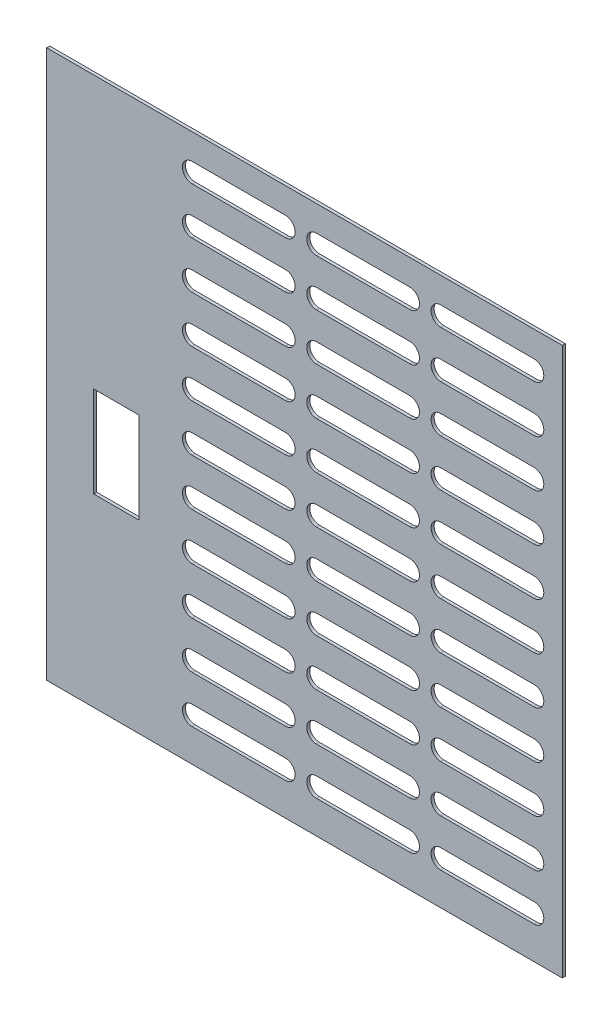
from build123d import *

# Parameters (mm, degrees)
ESBO_O1_W                = 170
ESBO_O1_H                = 180.654713277
RESSALTO_EXTRUS_O1_DEPTH = 1


with BuildPart() as part:
    # Esboço1 → Ressalto-extrusão1 (new body)
    with BuildSketch(Plane.XY):
        with Locations((-120, 100.327356639)):
            Rectangle(ESBO_O1_W, ESBO_O1_H)
        with BuildLine():
            Line((-116.056042092, 182.171109309), (-85.285782991, 182.171109309))
            ThreePointArc((-85.285782991, 182.171109309), (-82.089523647, 178.974849965), (-85.285782991, 175.778590621))
            Line((-85.285782991, 175.778590621), (-116.056042092, 175.778590621))
            ThreePointArc((-116.056042092, 175.778590621), (-119.252301436, 178.974849965), (-116.056042092, 182.171109309))
        make_face(mode=Mode.SUBTRACT)
        with BuildLine():
            Line((-75.056042092, 182.171109309), (-44.285782991, 182.171109309))
            ThreePointArc((-44.285782991, 182.171109309), (-41.089523647, 178.974849965), (-44.285782991, 175.778590621))
            Line((-44.285782991, 175.778590621), (-75.056042092, 175.778590621))
            ThreePointArc((-75.056042092, 175.778590621), (-78.252301436, 178.974849965), (-75.056042092, 182.171109309))
        make_face(mode=Mode.SUBTRACT)
        with BuildLine():
            Line((-157.056042092, 182.171109309), (-126.285782991, 182.171109309))
            ThreePointArc((-126.285782991, 182.171109309), (-123.089523647, 178.974849965), (-126.285782991, 175.778590621))
            Line((-126.285782991, 175.778590621), (-157.056042092, 175.778590621))
            ThreePointArc((-157.056042092, 175.778590621), (-160.252301436, 178.974849965), (-157.056042092, 182.171109309))
        make_face(mode=Mode.SUBTRACT)
        with BuildLine():
            Line((-116.056042092, 166.671109309), (-85.285782991, 166.671109309))
            ThreePointArc((-85.285782991, 166.671109309), (-82.089523647, 163.474849965), (-85.285782991, 160.278590621))
            Line((-85.285782991, 160.278590621), (-116.056042092, 160.278590621))
            ThreePointArc((-116.056042092, 160.278590621), (-119.252301436, 163.474849965), (-116.056042092, 166.671109309))
        make_face(mode=Mode.SUBTRACT)
        with BuildLine():
            Line((-75.056042092, 166.671109309), (-44.285782991, 166.671109309))
            ThreePointArc((-44.285782991, 166.671109309), (-41.089523647, 163.474849965), (-44.285782991, 160.278590621))
            Line((-44.285782991, 160.278590621), (-75.056042092, 160.278590621))
            ThreePointArc((-75.056042092, 160.278590621), (-78.252301436, 163.474849965), (-75.056042092, 166.671109309))
        make_face(mode=Mode.SUBTRACT)
        with BuildLine():
            Line((-116.056042092, 151.171109309), (-85.285782991, 151.171109309))
            ThreePointArc((-85.285782991, 151.171109309), (-82.089523647, 147.974849965), (-85.285782991, 144.778590621))
            Line((-85.285782991, 144.778590621), (-116.056042092, 144.778590621))
            ThreePointArc((-116.056042092, 144.778590621), (-119.252301436, 147.974849965), (-116.056042092, 151.171109309))
        make_face(mode=Mode.SUBTRACT)
        with BuildLine():
            Line((-75.056042092, 151.171109309), (-44.285782991, 151.171109309))
            ThreePointArc((-44.285782991, 151.171109309), (-41.089523647, 147.974849965), (-44.285782991, 144.778590621))
            Line((-44.285782991, 144.778590621), (-75.056042092, 144.778590621))
            ThreePointArc((-75.056042092, 144.778590621), (-78.252301436, 147.974849965), (-75.056042092, 151.171109309))
        make_face(mode=Mode.SUBTRACT)
        with BuildLine():
            Line((-116.056042092, 135.671109309), (-85.285782991, 135.671109309))
            ThreePointArc((-85.285782991, 135.671109309), (-82.089523647, 132.474849965), (-85.285782991, 129.278590621))
            Line((-85.285782991, 129.278590621), (-116.056042092, 129.278590621))
            ThreePointArc((-116.056042092, 129.278590621), (-119.252301436, 132.474849965), (-116.056042092, 135.671109309))
        make_face(mode=Mode.SUBTRACT)
        with BuildLine():
            Line((-75.056042092, 135.671109309), (-44.285782991, 135.671109309))
            ThreePointArc((-44.285782991, 135.671109309), (-41.089523647, 132.474849965), (-44.285782991, 129.278590621))
            Line((-44.285782991, 129.278590621), (-75.056042092, 129.278590621))
            ThreePointArc((-75.056042092, 129.278590621), (-78.252301436, 132.474849965), (-75.056042092, 135.671109309))
        make_face(mode=Mode.SUBTRACT)
        with BuildLine():
            Line((-116.056042092, 120.171109309), (-85.285782991, 120.171109309))
            ThreePointArc((-85.285782991, 120.171109309), (-82.089523647, 116.974849965), (-85.285782991, 113.778590621))
            Line((-85.285782991, 113.778590621), (-116.056042092, 113.778590621))
            ThreePointArc((-116.056042092, 113.778590621), (-119.252301436, 116.974849965), (-116.056042092, 120.171109309))
        make_face(mode=Mode.SUBTRACT)
        with BuildLine():
            Line((-75.056042092, 120.171109309), (-44.285782991, 120.171109309))
            ThreePointArc((-44.285782991, 120.171109309), (-41.089523647, 116.974849965), (-44.285782991, 113.778590621))
            Line((-44.285782991, 113.778590621), (-75.056042092, 113.778590621))
            ThreePointArc((-75.056042092, 113.778590621), (-78.252301436, 116.974849965), (-75.056042092, 120.171109309))
        make_face(mode=Mode.SUBTRACT)
        with BuildLine():
            Line((-116.056042092, 104.671109309), (-85.285782991, 104.671109309))
            ThreePointArc((-85.285782991, 104.671109309), (-82.089523647, 101.474849965), (-85.285782991, 98.278590621))
            Line((-85.285782991, 98.278590621), (-116.056042092, 98.278590621))
            ThreePointArc((-116.056042092, 98.278590621), (-119.252301436, 101.474849965), (-116.056042092, 104.671109309))
        make_face(mode=Mode.SUBTRACT)
        with BuildLine():
            Line((-75.056042092, 104.671109309), (-44.285782991, 104.671109309))
            ThreePointArc((-44.285782991, 104.671109309), (-41.089523647, 101.474849965), (-44.285782991, 98.278590621))
            Line((-44.285782991, 98.278590621), (-75.056042092, 98.278590621))
            ThreePointArc((-75.056042092, 98.278590621), (-78.252301436, 101.474849965), (-75.056042092, 104.671109309))
        make_face(mode=Mode.SUBTRACT)
        with BuildLine():
            Line((-116.056042092, 89.171109309), (-85.285782991, 89.171109309))
            ThreePointArc((-85.285782991, 89.171109309), (-82.089523647, 85.974849965), (-85.285782991, 82.778590621))
            Line((-85.285782991, 82.778590621), (-116.056042092, 82.778590621))
            ThreePointArc((-116.056042092, 82.778590621), (-119.252301436, 85.974849965), (-116.056042092, 89.171109309))
        make_face(mode=Mode.SUBTRACT)
        with BuildLine():
            Line((-75.056042092, 89.171109309), (-44.285782991, 89.171109309))
            ThreePointArc((-44.285782991, 89.171109309), (-41.089523647, 85.974849965), (-44.285782991, 82.778590621))
            Line((-44.285782991, 82.778590621), (-75.056042092, 82.778590621))
            ThreePointArc((-75.056042092, 82.778590621), (-78.252301436, 85.974849965), (-75.056042092, 89.171109309))
        make_face(mode=Mode.SUBTRACT)
        with BuildLine():
            Line((-116.056042092, 73.671109309), (-85.285782991, 73.671109309))
            ThreePointArc((-85.285782991, 73.671109309), (-82.089523647, 70.474849965), (-85.285782991, 67.278590621))
            Line((-85.285782991, 67.278590621), (-116.056042092, 67.278590621))
            ThreePointArc((-116.056042092, 67.278590621), (-119.252301436, 70.474849965), (-116.056042092, 73.671109309))
        make_face(mode=Mode.SUBTRACT)
        with BuildLine():
            Line((-75.056042092, 73.671109309), (-44.285782991, 73.671109309))
            ThreePointArc((-44.285782991, 73.671109309), (-41.089523647, 70.474849965), (-44.285782991, 67.278590621))
            Line((-44.285782991, 67.278590621), (-75.056042092, 67.278590621))
            ThreePointArc((-75.056042092, 67.278590621), (-78.252301436, 70.474849965), (-75.056042092, 73.671109309))
        make_face(mode=Mode.SUBTRACT)
        with BuildLine():
            Line((-116.056042092, 58.171109309), (-85.285782991, 58.171109309))
            ThreePointArc((-85.285782991, 58.171109309), (-82.089523647, 54.974849965), (-85.285782991, 51.778590621))
            Line((-85.285782991, 51.778590621), (-116.056042092, 51.778590621))
            ThreePointArc((-116.056042092, 51.778590621), (-119.252301436, 54.974849965), (-116.056042092, 58.171109309))
        make_face(mode=Mode.SUBTRACT)
        with BuildLine():
            Line((-75.056042092, 58.171109309), (-44.285782991, 58.171109309))
            ThreePointArc((-44.285782991, 58.171109309), (-41.089523647, 54.974849965), (-44.285782991, 51.778590621))
            Line((-44.285782991, 51.778590621), (-75.056042092, 51.778590621))
            ThreePointArc((-75.056042092, 51.778590621), (-78.252301436, 54.974849965), (-75.056042092, 58.171109309))
        make_face(mode=Mode.SUBTRACT)
        with BuildLine():
            Line((-116.056042092, 42.671109309), (-85.285782991, 42.671109309))
            ThreePointArc((-85.285782991, 42.671109309), (-82.089523647, 39.474849965), (-85.285782991, 36.278590621))
            Line((-85.285782991, 36.278590621), (-116.056042092, 36.278590621))
            ThreePointArc((-116.056042092, 36.278590621), (-119.252301436, 39.474849965), (-116.056042092, 42.671109309))
        make_face(mode=Mode.SUBTRACT)
        with BuildLine():
            Line((-75.056042092, 42.671109309), (-44.285782991, 42.671109309))
            ThreePointArc((-44.285782991, 42.671109309), (-41.089523647, 39.474849965), (-44.285782991, 36.278590621))
            Line((-44.285782991, 36.278590621), (-75.056042092, 36.278590621))
            ThreePointArc((-75.056042092, 36.278590621), (-78.252301436, 39.474849965), (-75.056042092, 42.671109309))
        make_face(mode=Mode.SUBTRACT)
        with BuildLine():
            Line((-116.056042092, 27.171109309), (-85.285782991, 27.171109309))
            ThreePointArc((-85.285782991, 27.171109309), (-82.089523647, 23.974849965), (-85.285782991, 20.778590621))
            Line((-85.285782991, 20.778590621), (-116.056042092, 20.778590621))
            ThreePointArc((-116.056042092, 20.778590621), (-119.252301436, 23.974849965), (-116.056042092, 27.171109309))
        make_face(mode=Mode.SUBTRACT)
        with BuildLine():
            Line((-75.056042092, 27.171109309), (-44.285782991, 27.171109309))
            ThreePointArc((-44.285782991, 27.171109309), (-41.089523647, 23.974849965), (-44.285782991, 20.778590621))
            Line((-44.285782991, 20.778590621), (-75.056042092, 20.778590621))
            ThreePointArc((-75.056042092, 20.778590621), (-78.252301436, 23.974849965), (-75.056042092, 27.171109309))
        make_face(mode=Mode.SUBTRACT)
        with BuildLine():
            Line((-157.056042092, 166.671109309), (-126.285782991, 166.671109309))
            ThreePointArc((-126.285782991, 166.671109309), (-123.089523647, 163.474849965), (-126.285782991, 160.278590621))
            Line((-126.285782991, 160.278590621), (-157.056042092, 160.278590621))
            ThreePointArc((-157.056042092, 160.278590621), (-160.252301436, 163.474849965), (-157.056042092, 166.671109309))
        make_face(mode=Mode.SUBTRACT)
        with BuildLine():
            Line((-157.056042092, 151.171109309), (-126.285782991, 151.171109309))
            ThreePointArc((-126.285782991, 151.171109309), (-123.089523647, 147.974849965), (-126.285782991, 144.778590621))
            Line((-126.285782991, 144.778590621), (-157.056042092, 144.778590621))
            ThreePointArc((-157.056042092, 144.778590621), (-160.252301436, 147.974849965), (-157.056042092, 151.171109309))
        make_face(mode=Mode.SUBTRACT)
        with BuildLine():
            Line((-157.056042092, 135.671109309), (-126.285782991, 135.671109309))
            ThreePointArc((-126.285782991, 135.671109309), (-123.089523647, 132.474849965), (-126.285782991, 129.278590621))
            Line((-126.285782991, 129.278590621), (-157.056042092, 129.278590621))
            ThreePointArc((-157.056042092, 129.278590621), (-160.252301436, 132.474849965), (-157.056042092, 135.671109309))
        make_face(mode=Mode.SUBTRACT)
        with BuildLine():
            Line((-157.056042092, 120.171109309), (-126.285782991, 120.171109309))
            ThreePointArc((-126.285782991, 120.171109309), (-123.089523647, 116.974849965), (-126.285782991, 113.778590621))
            Line((-126.285782991, 113.778590621), (-157.056042092, 113.778590621))
            ThreePointArc((-157.056042092, 113.778590621), (-160.252301436, 116.974849965), (-157.056042092, 120.171109309))
        make_face(mode=Mode.SUBTRACT)
        with BuildLine():
            Line((-157.056042092, 104.671109309), (-126.285782991, 104.671109309))
            ThreePointArc((-126.285782991, 104.671109309), (-123.089523647, 101.474849965), (-126.285782991, 98.278590621))
            Line((-126.285782991, 98.278590621), (-157.056042092, 98.278590621))
            ThreePointArc((-157.056042092, 98.278590621), (-160.252301436, 101.474849965), (-157.056042092, 104.671109309))
        make_face(mode=Mode.SUBTRACT)
        with BuildLine():
            Line((-157.056042092, 89.171109309), (-126.285782991, 89.171109309))
            ThreePointArc((-126.285782991, 89.171109309), (-123.089523647, 85.974849965), (-126.285782991, 82.778590621))
            Line((-126.285782991, 82.778590621), (-157.056042092, 82.778590621))
            ThreePointArc((-157.056042092, 82.778590621), (-160.252301436, 85.974849965), (-157.056042092, 89.171109309))
        make_face(mode=Mode.SUBTRACT)
        with BuildLine():
            Line((-157.056042092, 73.671109309), (-126.285782991, 73.671109309))
            ThreePointArc((-126.285782991, 73.671109309), (-123.089523647, 70.474849965), (-126.285782991, 67.278590621))
            Line((-126.285782991, 67.278590621), (-157.056042092, 67.278590621))
            ThreePointArc((-157.056042092, 67.278590621), (-160.252301436, 70.474849965), (-157.056042092, 73.671109309))
        make_face(mode=Mode.SUBTRACT)
        with BuildLine():
            Line((-157.056042092, 58.171109309), (-126.285782991, 58.171109309))
            ThreePointArc((-126.285782991, 58.171109309), (-123.089523647, 54.974849965), (-126.285782991, 51.778590621))
            Line((-126.285782991, 51.778590621), (-157.056042092, 51.778590621))
            ThreePointArc((-157.056042092, 51.778590621), (-160.252301436, 54.974849965), (-157.056042092, 58.171109309))
        make_face(mode=Mode.SUBTRACT)
        with BuildLine():
            Line((-157.056042092, 42.671109309), (-126.285782991, 42.671109309))
            ThreePointArc((-126.285782991, 42.671109309), (-123.089523647, 39.474849965), (-126.285782991, 36.278590621))
            Line((-126.285782991, 36.278590621), (-157.056042092, 36.278590621))
            ThreePointArc((-157.056042092, 36.278590621), (-160.252301436, 39.474849965), (-157.056042092, 42.671109309))
        make_face(mode=Mode.SUBTRACT)
        with BuildLine():
            Line((-157.056042092, 27.171109309), (-126.285782991, 27.171109309))
            ThreePointArc((-126.285782991, 27.171109309), (-123.089523647, 23.974849965), (-126.285782991, 20.778590621))
            Line((-126.285782991, 20.778590621), (-157.056042092, 20.778590621))
            ThreePointArc((-157.056042092, 20.778590621), (-160.252301436, 23.974849965), (-157.056042092, 27.171109309))
        make_face(mode=Mode.SUBTRACT)
        Polygon((-174.500838333, 85.974849965), (-174.500838333, 70.974849965), (-189.500838333, 70.974849965), (-189.500838333, 100.974849965), (-174.500838333, 100.974849965), align=None, mode=Mode.SUBTRACT)
    extrude(amount=RESSALTO_EXTRUS_O1_DEPTH)


solid = part.part
